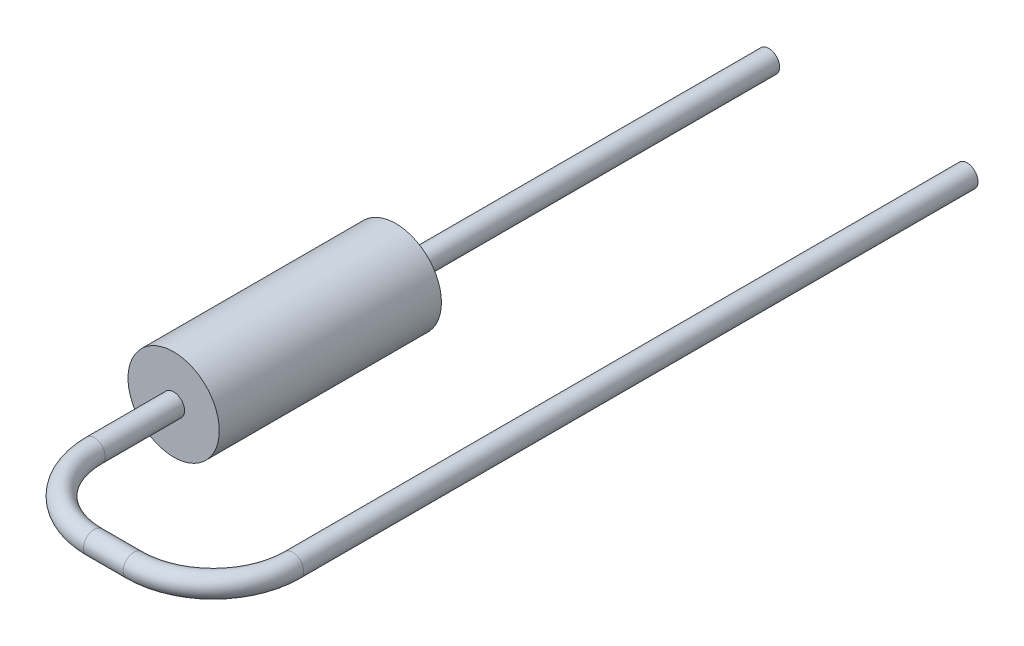
from build123d import *

# Parameters (mm, degrees)
SKETCH2_R           = 1.15
RESISTOR_BODY_DEPTH = 5.6
LEAD1_PROFILE_R     = 0.275
SKETCH6_R           = 0.275
LEAD2_DEPTH         = 9.4


with BuildPart() as part:
    # Sketch2 → Resistor Body (new body)
    with BuildSketch(Plane.XY):
        Circle(SKETCH2_R)
    extrude(amount=RESISTOR_BODY_DEPTH)

    # Lead1: sweep along a path in Lead1 Path
    with BuildLine(Plane(origin=(0, 0, 0), x_dir=(1, 0, 0), z_dir=(0, 1, 0))) as lead1_path:
        Line((0, -5.6), (0, -7.6))
        ThreePointArc((0, -7.6), (0.585786438, -9.014213562), (2, -9.6))
        Line((2, -9.6), (3, -9.6))
        ThreePointArc((3, -9.6), (4.414213562, -9.014213562), (5, -7.6))
        Line((5, -7.6), (5, 9.4))
    # Lead1 Profile → Lead1 (sweep)
    with BuildSketch(Plane(origin=(0, 0, 5.6), x_dir=(-1, 0, 0), z_dir=(0, 0, 1))):
        Circle(LEAD1_PROFILE_R)
    sweep(path=lead1_path.line)

    # Sketch6 → Lead2 (add)
    with BuildSketch(Plane(origin=(0, 0, 0), x_dir=(1, 0, 0), z_dir=(0, 0, -1))):
        Circle(SKETCH6_R)
    extrude(amount=LEAD2_DEPTH)


solid = part.part
